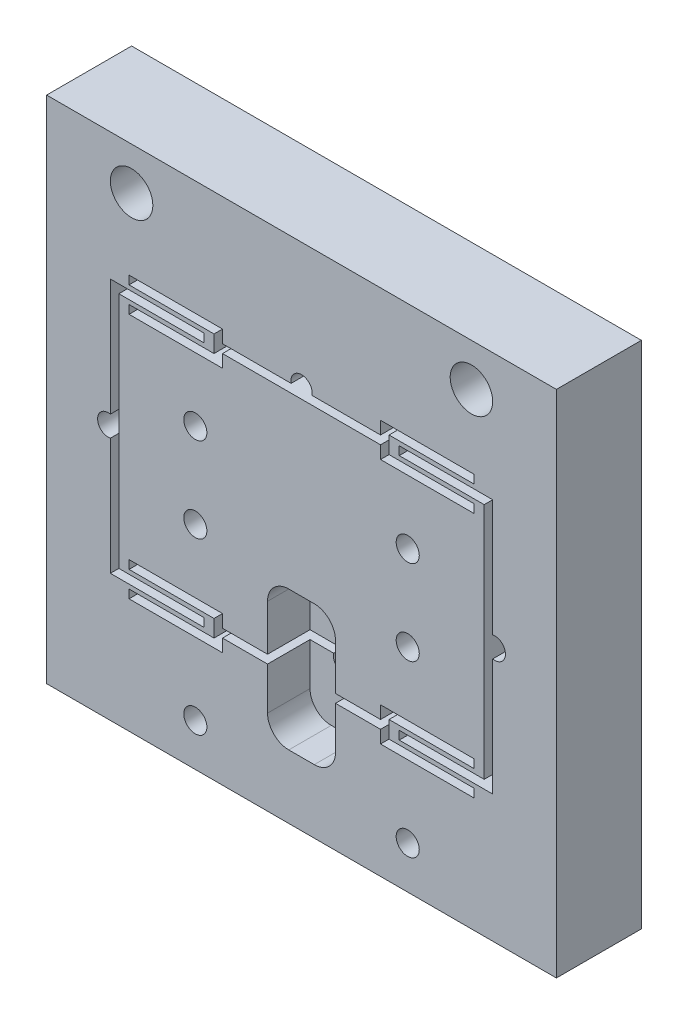
from build123d import *

# Parameters (mm, degrees)
SKETCH1_W                       = 76.2
SKETCH1_H                       = 76.2
BOSS_EXTRUDE1_DEPTH             = 6.35
CUT_EXTRUDE1_DEPTH              = 12.7
CUT_EXTRUDE2_DEPTH              = 12.7
F_1_4_0_25_DIAMETER_HOLE1_D     = 6.35
F_1_4_0_25_DIAMETER_HOLE1_DEPTH = 12.7
F_8_32_TAPPED_HOLE1_D           = 3.4544
F_8_32_TAPPED_HOLE1_DEPTH       = 12.7
SKETCH8_W                       = 10.16
SKETCH8_H                       = 20.828
CUT_EXTRUDE3_DEPTH              = 6.35
FILLET1_R                       = 3.175
FILLET2_R                       = 3.175
FILLET3_R                       = 3.175
FILLET4_R                       = 3.175
CUT_EXTRUDE6_REACH              = 14.7
SKETCH11_R                      = 1.5875


with BuildPart() as part:
    # Sketch1 → Boss-Extrude1 (new body, symmetric)
    with BuildSketch(Plane.XY):
        Rectangle(SKETCH1_W, SKETCH1_H)
    extrude(amount=BOSS_EXTRUDE1_DEPTH, both=True)

    # Sketch2 → Cut-Extrude1 (cut)
    with BuildSketch(Plane.XY.offset(6.35)):
        Polygon((14.605, 19.05), (28.575, 19.05), (28.575, -19.05), (14.605, -19.05), (14.605, -17.78), (27.305, -17.78), (27.305, 17.78), (14.605, 17.78), align=None)
    cut_extrude1 = extrude(amount=-CUT_EXTRUDE1_DEPTH, mode=Mode.SUBTRACT)

    # Mirror1: Cut-Extrude1 across plane
    add(cut_extrude1.mirror(Plane(origin=(0, 0, 0), x_dir=(0, 0, 1), z_dir=(1, 0, 0))), mode=Mode.SUBTRACT)

    # Sketch3 → Cut-Extrude2 (cut)
    with BuildSketch(Plane.XY.offset(6.35)):
        Polygon((25.781, 17.145), (25.781, 15.875), (11.811, 15.875), (11.811, 17.78), (-11.811, 17.78), (-11.811, 15.875), (-25.781, 15.875), (-25.781, 17.145), (-13.081, 17.145), (-13.081, 19.685), (-25.781, 19.685), (-25.781, 20.955), (-11.811, 20.955), (-11.811, 19.05), (11.811, 19.05), (11.811, 20.955), (25.781, 20.955), (25.781, 19.685), (13.081, 19.685), (13.081, 17.145), align=None)
    cut_extrude2 = extrude(amount=-CUT_EXTRUDE2_DEPTH, mode=Mode.SUBTRACT)

    # Mirror2: Cut-Extrude2 across plane
    add(cut_extrude2.mirror(Plane.ZX), mode=Mode.SUBTRACT)

    # 1/4 (0.25) Diameter Hole1
    with Locations(Plane.XY.offset(6.35)):
        with Locations((-25.4, 31.75), (25.4, 31.75)):
            Hole(F_1_4_0_25_DIAMETER_HOLE1_D / 2, depth=F_1_4_0_25_DIAMETER_HOLE1_DEPTH)

    # #8-32 Tapped Hole1
    with Locations(Plane.XY.offset(6.35)):
        with Locations((-15.875, 6.35), (15.875, 6.35), (15.875, -6.35), (-15.875, -6.35), (-15.875, -31.75), (15.875, -31.75)):
            Hole(F_8_32_TAPPED_HOLE1_D / 2, depth=F_8_32_TAPPED_HOLE1_DEPTH)

    # Sketch8 → Cut-Extrude3 (cut)
    with BuildSketch(Plane.XY.offset(6.35)):
        with Locations((0, -18.161)):
            Rectangle(SKETCH8_W, SKETCH8_H)
    extrude(amount=-CUT_EXTRUDE3_DEPTH, mode=Mode.SUBTRACT)

    # Fillet1
    fillet1_edges = [part.edges().sort_by_distance(p)[0] for p in [
        (-5.08, -7.747, 3.175),
    ]]
    fillet(fillet1_edges, radius=FILLET1_R)

    # Fillet2
    fillet2_edges = [part.edges().sort_by_distance(p)[0] for p in [
        (-5.08, -28.575, 3.175),
    ]]
    fillet(fillet2_edges, radius=FILLET2_R)

    # Fillet3
    fillet3_edges = [part.edges().sort_by_distance(p)[0] for p in [
        (5.08, -7.747, 3.175),
    ]]
    fillet(fillet3_edges, radius=FILLET3_R)

    # Fillet4
    fillet4_edges = [part.edges().sort_by_distance(p)[0] for p in [
        (5.08, -28.575, 3.175),
    ]]
    fillet(fillet4_edges, radius=FILLET4_R)

    # Sketch11 → Cut-Extrude6 (cut, up to next)
    with BuildSketch(Plane.XY.offset(6.35), mode=Mode.PRIVATE) as cut_extrude6_sk1:
        with Locations((0, 19.3675)):
            Circle(SKETCH11_R)
    cut_extrude6_tool1 = extrude(cut_extrude6_sk1.sketch, amount=-CUT_EXTRUDE6_REACH, mode=Mode.PRIVATE) & part.part
    add(cut_extrude6_tool1.solids().sort_by_distance((0, 19.3675, 6.35))[0], mode=Mode.SUBTRACT)
    # Sketch11 → Cut-Extrude6 (cut, up to next)
    with BuildSketch(Plane.XY.offset(6.35), mode=Mode.PRIVATE) as cut_extrude6_sk2:
        with Locations((28.8925, 0)):
            Circle(SKETCH11_R)
    cut_extrude6_tool2 = extrude(cut_extrude6_sk2.sketch, amount=-CUT_EXTRUDE6_REACH, mode=Mode.PRIVATE) & part.part
    add(cut_extrude6_tool2.solids().sort_by_distance((28.8925, 0, 6.35))[0], mode=Mode.SUBTRACT)
    # Sketch11 → Cut-Extrude6 (cut, up to next)
    with BuildSketch(Plane.XY.offset(6.35), mode=Mode.PRIVATE) as cut_extrude6_sk3:
        with Locations((0, -19.3675)):
            Circle(SKETCH11_R)
    cut_extrude6_tool3 = extrude(cut_extrude6_sk3.sketch, amount=-CUT_EXTRUDE6_REACH, mode=Mode.PRIVATE) & part.part
    add(cut_extrude6_tool3.solids().sort_by_distance((0, -19.3675, 6.35))[0], mode=Mode.SUBTRACT)
    # Sketch11 → Cut-Extrude6 (cut, up to next)
    with BuildSketch(Plane.XY.offset(6.35), mode=Mode.PRIVATE) as cut_extrude6_sk4:
        with Locations((-28.8925, 0)):
            Circle(SKETCH11_R)
    cut_extrude6_tool4 = extrude(cut_extrude6_sk4.sketch, amount=-CUT_EXTRUDE6_REACH, mode=Mode.PRIVATE) & part.part
    add(cut_extrude6_tool4.solids().sort_by_distance((-28.8925, 0, 6.35))[0], mode=Mode.SUBTRACT)


solid = part.part
